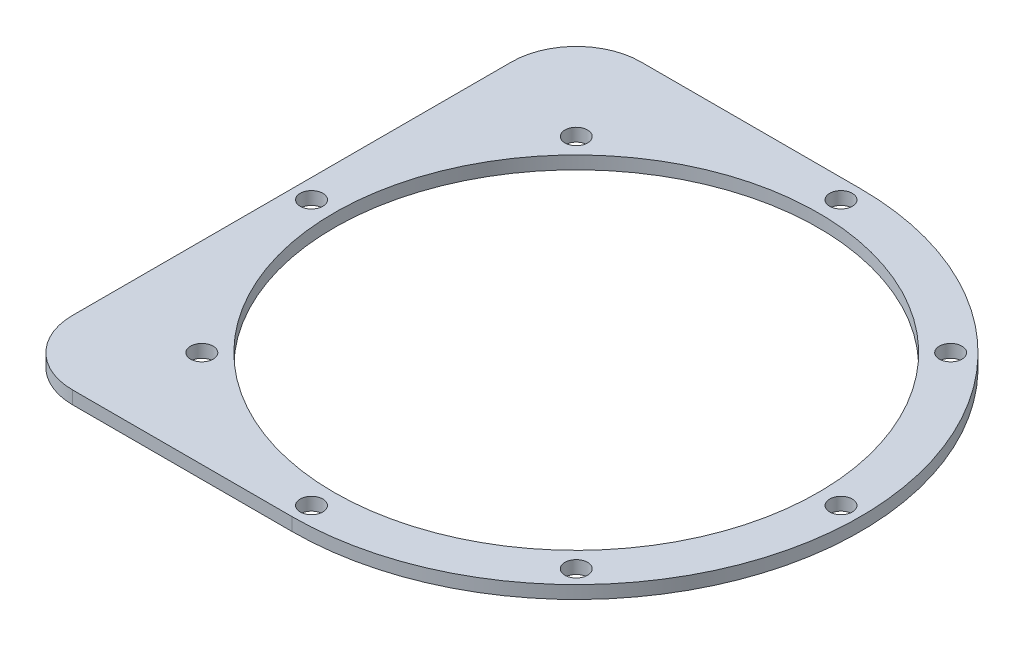
from build123d import *

# Parameters (mm, degrees)
SKETCH1_R           = 44
BOSS_EXTRUDE1_DEPTH = 2
SKETCH2_W           = 44
SKETCH2_H           = 88
BOSS_EXTRUDE2_DEPTH = 2
SKETCH3_R           = 1.75
CUT_EXTRUDE1_DEPTH  = 3
CIRPATTERN1_COUNT   = 8
SKETCH4_R           = 37.5
CUT_EXTRUDE2_DEPTH  = 3
FILLET1_R           = 10


with BuildPart() as part:
    # Sketch1 → Boss-Extrude1 (new body)
    with BuildSketch(Plane(origin=(0, 0, 0), x_dir=(1, 0, 0), z_dir=(0, 1, 0))):
        Circle(SKETCH1_R)
    extrude(amount=BOSS_EXTRUDE1_DEPTH)

    # Sketch2 → Boss-Extrude2 (add)
    with BuildSketch(Plane(origin=(0, 2, 0), x_dir=(1, 0, 0), z_dir=(0, 1, 0))):
        with Locations((-22, 0)):
            Rectangle(SKETCH2_W, SKETCH2_H)
    extrude(amount=-BOSS_EXTRUDE2_DEPTH)

    # Sketch3 → Cut-Extrude1 (cut, through all)
    with BuildSketch(Plane(origin=(0, 2, 0), x_dir=(1, 0, 0), z_dir=(0, 1, 0))):
        with Locations((41, 0)):
            Circle(SKETCH3_R)
    cut_extrude1 = extrude(amount=-CUT_EXTRUDE1_DEPTH, mode=Mode.SUBTRACT)

    # CirPattern1: Cut-Extrude1 ×8 about axis
    cirpattern1_axis = Axis((0, 0, 0), (0, 1, 0))
    for i in range(1, CIRPATTERN1_COUNT):
        add(cut_extrude1.rotate(cirpattern1_axis, i * 360 / CIRPATTERN1_COUNT), mode=Mode.SUBTRACT)

    # Sketch4 → Cut-Extrude2 (cut, through all)
    with BuildSketch(Plane(origin=(0, 2, 0), x_dir=(1, 0, 0), z_dir=(0, 1, 0))):
        Circle(SKETCH4_R)
    extrude(amount=-CUT_EXTRUDE2_DEPTH, mode=Mode.SUBTRACT)

    # Fillet1
    fillet1_edges = [part.edges().sort_by_distance(p)[0] for p in [
        (-44, 1, 44),
        (-44, 1, -44),
    ]]
    fillet(fillet1_edges, radius=FILLET1_R)


solid = part.part
